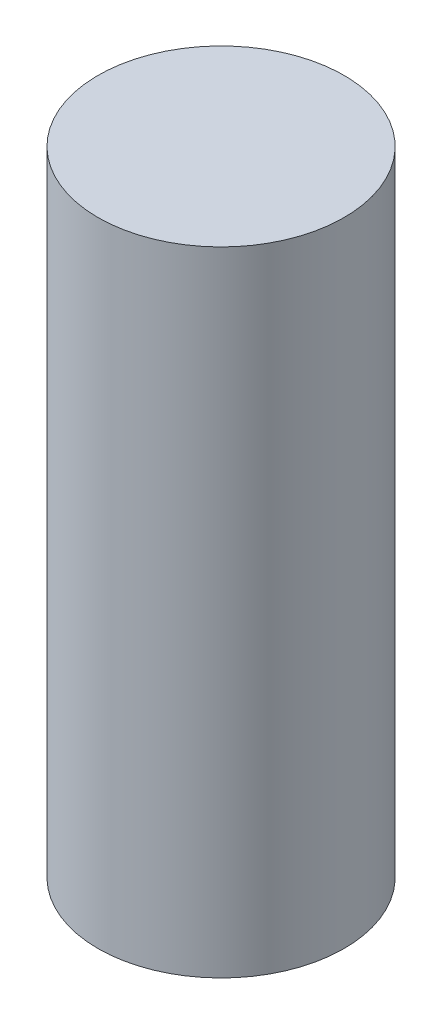
from build123d import *

# Parameters (mm, degrees)
SKETCH1_R           = 1.75
BOSS_EXTRUDE1_DEPTH = 9


with BuildPart() as part:
    # Sketch1 → Boss-Extrude1 (new body)
    with BuildSketch(Plane(origin=(0, 0, 0), x_dir=(1, 0, 0), z_dir=(0, 1, 0))):
        Circle(SKETCH1_R)
    extrude(amount=BOSS_EXTRUDE1_DEPTH)


solid = part.part
